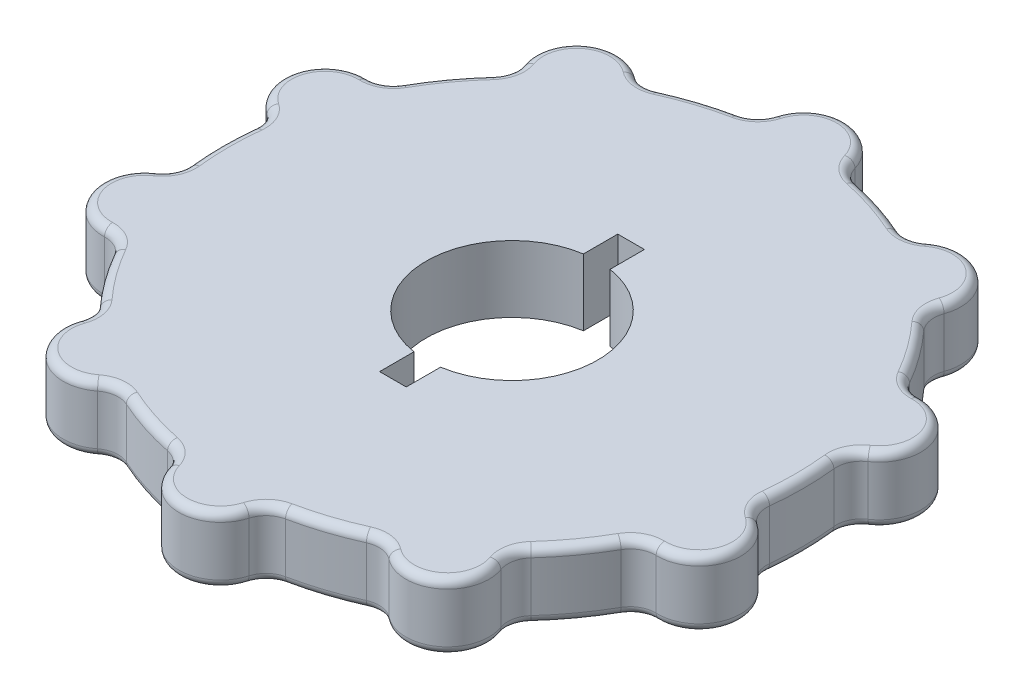
from build123d import *

# Parameters (mm, degrees)
SKETCH_1_R               = 40
SKETCH_1_R_2             = 10.3
EXTRUDE_1_DEPTH          = 8
CUT_EXTRUDE_1_DEPTH      = 9
FILLET_1_R               = 1
SKETCH_3_W               = 3.2
SKETCH_3_H               = 8
CUT_EXTRUDE_2_DEPTH      = 9.0000001
PATTERN_CIRCULAR_1_COUNT = 2


with BuildPart() as part:
    # 草图1 → 凸台-拉伸1 (new body)
    with BuildSketch(Plane(origin=(0, 0, 0), x_dir=(1, 0, 0), z_dir=(0, 1, 0))):
        Circle(SKETCH_1_R)
        Circle(SKETCH_1_R_2, mode=Mode.SUBTRACT)
    extrude(amount=EXTRUDE_1_DEPTH)

    # 草图2 → 切除-拉伸1 (cut, through all)
    with BuildSketch(Plane(origin=(0, 8, 0), x_dir=(1, 0, 0), z_dir=(0, 1, 0))):
        with BuildLine():
            ThreePointArc((-34.786723495, -3.8579617), (-35, 0), (-34.786723495, 3.8579617))
            ThreePointArc((-34.786723495, 3.8579617), (-35.045144389, 5.447074333), (-36.087893434, 6.673750633))
            ThreePointArc((-36.087893434, 6.673750633), (-38.01554268, 9.190578886), (-38.04226052, 12.360680182))
            ThreePointArc((-38.04226052, 12.360680182), (-40, -5.3e-08), (-38.042260487, -12.360680283))
            ThreePointArc((-38.042260487, -12.360680283), (-38.015542697, -9.190578936), (-36.087893434, -6.673750633))
            ThreePointArc((-36.087893434, -6.673750633), (-35.045144389, -5.447074333), (-34.786723495, -3.8579617))
        make_face()
        with BuildLine():
            ThreePointArc((-33.118451279, -15.812753868), (-36.157306414, -14.909641114), (-38.042260487, -12.360680283))
            ThreePointArc((-38.042260487, -12.360680283), (-32.360679768, -23.511410101), (-23.511410505, -32.360679475))
            ThreePointArc((-23.511410505, -32.360679475), (-25.353133487, -29.780309403), (-25.272986879, -26.611109225))
            ThreePointArc((-25.272986879, -26.611109225), (-25.15040742, -25.005794741), (-25.875397495, -23.568279625))
            ThreePointArc((-25.875397495, -23.568279625), (-28.315594803, -20.57248383), (-30.410703477, -17.325966467))
            ThreePointArc((-30.410703477, -17.325966467), (-31.553827342, -16.192243332), (-33.118451279, -15.812753868))
        make_face()
        with BuildLine():
            ThreePointArc((-17.49888639, -32.259323848), (-20.488208718, -33.314884523), (-23.511410505, -32.360679475))
            ThreePointArc((-23.511410505, -32.360679475), (-12.360680018, -38.042260573), (0, -40))
            ThreePointArc((0, -40), (-3.006688972, -38.994974522), (-4.804658334, -36.383928571))
            ThreePointArc((-4.804658334, -36.383928571), (-5.649069648, -35.013151474), (-7.080549124, -34.276315789))
            ThreePointArc((-7.080549124, -34.276315789), (-10.815594803, -33.28697807), (-14.418828353, -31.891964332))
            ThreePointArc((-14.418828353, -31.891964332), (-16.010020725, -31.646674397), (-17.49888639, -32.259323848))
        make_face()
        with BuildLine():
            ThreePointArc((4.804658334, -36.383928571), (3.006688972, -38.994974522), (0, -40))
            ThreePointArc((0, -40), (12.360680018, -38.042260573), (23.511410505, -32.360679475))
            ThreePointArc((23.511410505, -32.360679475), (20.488208718, -33.314884523), (17.49888639, -32.259323848))
            ThreePointArc((17.49888639, -32.259323848), (16.010020725, -31.646674397), (14.418828353, -31.891964332))
            ThreePointArc((14.418828353, -31.891964332), (10.815594803, -33.28697807), (7.080549124, -34.276315789))
            ThreePointArc((7.080549124, -34.276315789), (5.649069648, -35.013151474), (4.804658334, -36.383928571))
        make_face()
        with BuildLine():
            ThreePointArc((23.511410505, -32.360679475), (32.360679799, -23.511410058), (38.04226052, -12.360680182))
            ThreePointArc((38.04226052, -12.360680182), (36.157306458, -14.909641084), (33.118451279, -15.812753868))
            ThreePointArc((33.118451279, -15.812753868), (31.553827342, -16.192243332), (30.410703477, -17.325966467))
            ThreePointArc((30.410703477, -17.325966467), (28.315594803, -20.57248383), (25.875397495, -23.568279625))
            ThreePointArc((25.875397495, -23.568279625), (25.15040742, -25.005794741), (25.272986879, -26.611109225))
            ThreePointArc((25.272986879, -26.611109225), (25.353133487, -29.780309403), (23.511410505, -32.360679475))
        make_face()
        with BuildLine():
            ThreePointArc((40, 0), (39.50753359, 6.257378813), (38.04226052, 12.360680182))
            ThreePointArc((38.04226052, 12.360680182), (38.01554268, 9.190578886), (36.087893434, 6.673750633))
            ThreePointArc((36.087893434, 6.673750633), (35.045144389, 5.447074333), (34.786723495, 3.8579617))
            ThreePointArc((34.786723495, 3.8579617), (35, 0), (34.786723495, -3.8579617))
            ThreePointArc((34.786723495, -3.8579617), (35.045144389, -5.447074333), (36.087893434, -6.673750633))
            ThreePointArc((36.087893434, -6.673750633), (38.01554268, -9.190578886), (38.04226052, -12.360680182))
            ThreePointArc((38.04226052, -12.360680182), (39.50753359, -6.257378813), (40, 0))
        make_face()
        with BuildLine():
            ThreePointArc((38.04226052, 12.360680182), (32.360679768, 23.511410101), (23.511410419, 32.360679537))
            ThreePointArc((23.511410419, 32.360679537), (25.353133471, 29.780309454), (25.272986879, 26.611109225))
            ThreePointArc((25.272986879, 26.611109225), (25.15040742, 25.005794741), (25.875397495, 23.568279625))
            ThreePointArc((25.875397495, 23.568279625), (28.315594803, 20.57248383), (30.410703477, 17.325966467))
            ThreePointArc((30.410703477, 17.325966467), (31.553827342, 16.192243332), (33.118451279, 15.812753868))
            ThreePointArc((33.118451279, 15.812753868), (36.157306458, 14.909641084), (38.04226052, 12.360680182))
        make_face()
        with BuildLine():
            ThreePointArc((23.511410419, 32.360679537), (12.360679968, 38.042260589), (0, 40))
            ThreePointArc((0, 40), (3.006688972, 38.994974522), (4.804658334, 36.383928571))
            ThreePointArc((4.804658334, 36.383928571), (5.649069648, 35.013151474), (7.080549124, 34.276315789))
            ThreePointArc((7.080549124, 34.276315789), (10.815594803, 33.28697807), (14.418828353, 31.891964332))
            ThreePointArc((14.418828353, 31.891964332), (16.010020725, 31.646674397), (17.49888639, 32.259323848))
            ThreePointArc((17.49888639, 32.259323848), (20.488208665, 33.314884522), (23.511410419, 32.360679537))
        make_face()
        with BuildLine():
            ThreePointArc((-14.418828353, 31.891964332), (-10.815594803, 33.28697807), (-7.080549124, 34.276315789))
            ThreePointArc((-7.080549124, 34.276315789), (-5.649069648, 35.013151474), (-4.804658334, 36.383928571))
            ThreePointArc((-4.804658334, 36.383928571), (-3.006688972, 38.994974522), (0, 40))
            ThreePointArc((0, 40), (-12.360679643, 38.042260695), (-23.511409866, 32.360679939))
            ThreePointArc((-23.511409866, 32.360679939), (-20.488208323, 33.314884517), (-17.49888639, 32.259323848))
            ThreePointArc((-17.49888639, 32.259323848), (-16.010020725, 31.646674397), (-14.418828353, 31.891964332))
        make_face()
        with BuildLine():
            ThreePointArc((-30.410703477, 17.325966467), (-28.315594803, 20.57248383), (-25.875397495, 23.568279625))
            ThreePointArc((-25.875397495, 23.568279625), (-25.15040742, 25.005794741), (-25.272986879, 26.611109225))
            ThreePointArc((-25.272986879, 26.611109225), (-25.353133371, 29.780309781), (-23.511409866, 32.360679939))
            ThreePointArc((-23.511409866, 32.360679939), (-32.360679568, 23.511410377), (-38.04226052, 12.360680182))
            ThreePointArc((-38.04226052, 12.360680182), (-36.157306458, 14.909641084), (-33.118451279, 15.812753868))
            ThreePointArc((-33.118451279, 15.812753868), (-31.553827342, 16.192243332), (-30.410703477, 17.325966467))
        make_face()
    extrude(amount=-CUT_EXTRUDE_1_DEPTH, mode=Mode.SUBTRACT)

    # 圆角1
    fillet_1_edges = [part.edges().sort_by_distance(p)[0] for p in [
        (-31.553827342, 0, 16.192243332),
        (-28.315594803, 8, 20.57248383),
        (-25.15040742, 0, 25.005794741),
        (-28.315594803, 0, 20.57248383),
        (-25.15040742, 8, 25.005794741),
        (-31.553827342, 8, 16.192243332),
        (5.649069648, 0, 35.013151474),
        (10.815594803, 8, 33.28697807),
        (16.010020725, 0, 31.646674397),
        (10.815594803, 0, 33.28697807),
        (16.010020725, 8, 31.646674397),
        (5.649069648, 8, 35.013151474),
        (35.045144389, 0, 5.447074333),
        (35, 8, 0),
        (35.045144389, 0, -5.447074333),
        (35, 0, 0),
        (35.045144389, 8, -5.447074333),
        (35.045144389, 8, 5.447074333),
        (16.010020725, 0, -31.646674397),
        (10.815594803, 8, -33.28697807),
        (5.649069648, 0, -35.013151474),
        (10.815594803, 0, -33.28697807),
        (5.649069648, 8, -35.013151474),
        (16.010020725, 8, -31.646674397),
        (-25.15040742, 0, -25.005794741),
        (-28.315594803, 8, -20.57248383),
        (-31.553827342, 0, -16.192243332),
        (-28.315594803, 0, -20.57248383),
        (-31.553827342, 8, -16.192243332),
        (-25.15040742, 8, -25.005794741),
        (-23.511410092, 8, -32.360679775),
        (0, 8, -40),
        (-5.649069648, 0, -35.013151474),
        (-10.815594803, 8, -33.28697807),
        (-16.010020725, 0, -31.646674397),
        (-23.511410092, 0, -32.360679775),
        (0, 0, -40),
        (-10.815594803, 0, -33.28697807),
        (-16.010020725, 8, -31.646674397),
        (-5.649069648, 8, -35.013151474),
        (-38.042260652, 8, -12.360679775),
        (-35.045144389, 0, -5.447074333),
        (-35, 8, 0),
        (-35.045144389, 0, 5.447074333),
        (-38.042260652, 8, 12.360679775),
        (-38.042260652, 0, -12.360679775),
        (-35, 0, 0),
        (-38.042260652, 0, 12.360679775),
        (-35.045144389, 8, 5.447074333),
        (-35.045144389, 8, -5.447074333),
        (-23.511410092, 8, 32.360679775),
        (-16.010020725, 0, 31.646674397),
        (-10.815594803, 8, 33.28697807),
        (-5.649069648, 0, 35.013151474),
        (0, 8, 40),
        (-23.511410092, 0, 32.360679775),
        (-10.815594803, 0, 33.28697807),
        (0, 0, 40),
        (-5.649069648, 8, 35.013151474),
        (-16.010020725, 8, 31.646674397),
        (23.511410092, 8, 32.360679775),
        (25.15040742, 0, 25.005794741),
        (28.315594803, 8, 20.57248383),
        (31.553827342, 0, 16.192243332),
        (38.042260652, 8, 12.360679775),
        (23.511410092, 0, 32.360679775),
        (28.315594803, 0, 20.57248383),
        (38.042260652, 0, 12.360679775),
        (31.553827342, 8, 16.192243332),
        (25.15040742, 8, 25.005794741),
        (38.042260652, 8, -12.360679775),
        (31.553827342, 0, -16.192243332),
        (28.315594803, 8, -20.57248383),
        (25.15040742, 0, -25.005794741),
        (23.511410092, 8, -32.360679775),
        (38.042260652, 0, -12.360679775),
        (28.315594803, 0, -20.57248383),
        (23.511410092, 0, -32.360679775),
        (25.15040742, 8, -25.005794741),
        (31.553827342, 8, -16.192243332),
    ]]
    fillet(fillet_1_edges, radius=FILLET_1_R)

    # 草图3 → 切除-拉伸2 (cut, through all)
    with BuildSketch(Plane.XZ):
        with Locations((0, 10.3)):
            Rectangle(SKETCH_3_W, SKETCH_3_H)
    cut_extrude_2 = extrude(amount=-CUT_EXTRUDE_2_DEPTH, mode=Mode.SUBTRACT)

    # 阵列(圆周)1: 切除-拉伸2 ×2 about axis
    pattern_circular_1_axis = Axis((0, 0, 0), (0, 1, 0))
    for i in range(1, PATTERN_CIRCULAR_1_COUNT):
        add(cut_extrude_2.rotate(pattern_circular_1_axis, i * 360 / PATTERN_CIRCULAR_1_COUNT), mode=Mode.SUBTRACT)


solid = part.part
